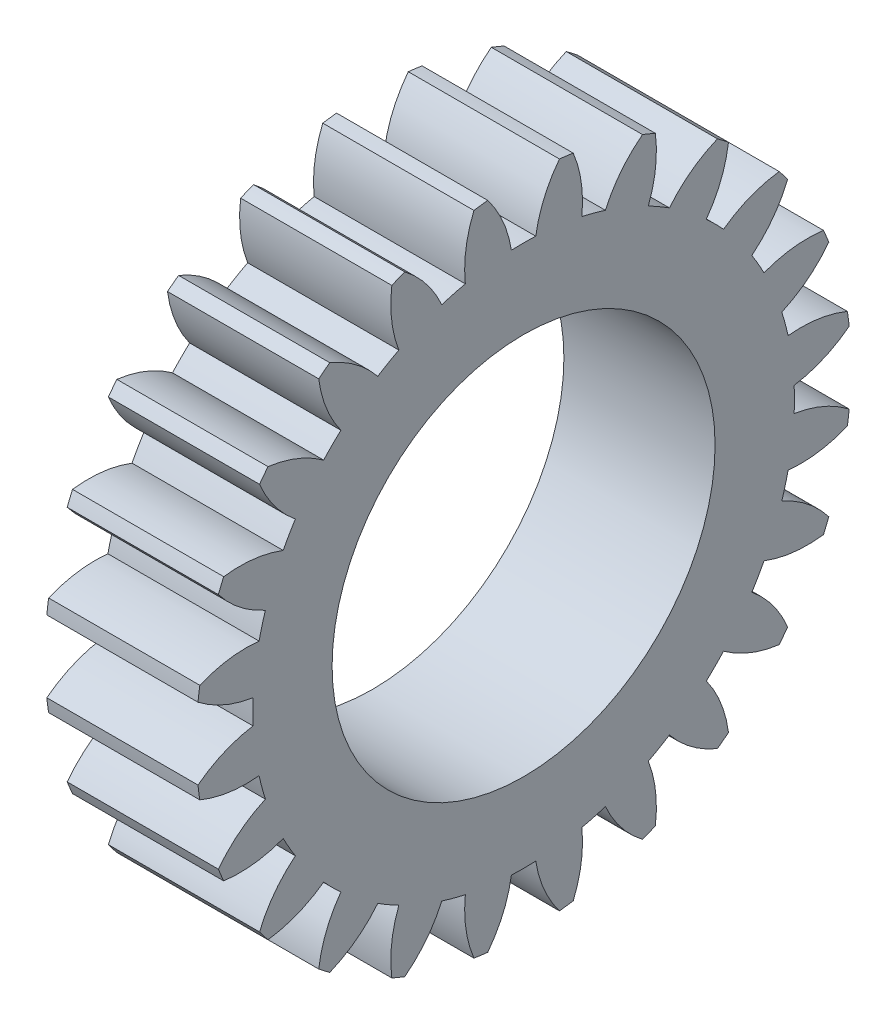
from build123d import *

# Parameters (mm, degrees)
BASPROSKE_W     = 6
BASPROSKE_H     = 13
TOOTHCUT_DEPTH  = 20.339079606
TEETHCUTS_COUNT = 24
TEETHCUTS_ANGLE = 345
BORSKE_R        = 7.6
BORE_DEPTH      = 50.0000508


with BuildPart() as part:
    # BasProSke → Base-Revolve (revolve)
    with BuildSketch(Plane(origin=(0, 0, 0), x_dir=(1, 0, 0), z_dir=(0, 1, 0)), mode=Mode.PRIVATE) as base_revolve_sk:
        with Locations((3, 6.5)):
            Rectangle(BASPROSKE_W, BASPROSKE_H)
    revolve(base_revolve_sk.sketch.rotate(Axis((-10, 0, 0), (1, 0, 0)), 180), axis=Axis((-10, 0, 0), (1, 0, 0)))

    # TooCutSke → ToothCut (cut, through all)
    with BuildSketch(Plane(origin=(0, 0, 0), x_dir=(0, 0, -1), z_dir=(1, 0, 0))):
        with BuildLine():
            ThreePointArc((0.483448384, 10.738122679), (0, 10.749), (-0.483448384, 10.738122679))
            ThreePointArc((-0.483448384, 10.738122679), (-0.821636462, 11.902754369), (-1.44092227, 12.945454344))
            ThreePointArc((-1.44092227, 12.945454344), (0, 13.0254), (1.44092227, 12.945454344))
            ThreePointArc((1.44092227, 12.945454344), (0.821636462, 11.902754369), (0.483448384, 10.738122679))
        make_face()
    toothcut = extrude(amount=TOOTHCUT_DEPTH, mode=Mode.SUBTRACT)

    # TeethCuts: ToothCut ×24 about axis
    teethcuts_axis = Axis((-10, 0, 0), (1, 0, 0))
    for i in range(1, TEETHCUTS_COUNT):
        add(toothcut.rotate(teethcuts_axis, i * TEETHCUTS_ANGLE / (TEETHCUTS_COUNT - 1)), mode=Mode.SUBTRACT)

    # BorSke → Bore (cut, symmetric)
    with BuildSketch(Plane(origin=(0, 0, 0), x_dir=(0, 0, -1), z_dir=(1, 0, 0))):
        with Locations(Location((0, 0, 0), (0, 0, 180))):
            Circle(BORSKE_R)
    extrude(amount=BORE_DEPTH, both=True, mode=Mode.SUBTRACT)


solid = part.part
